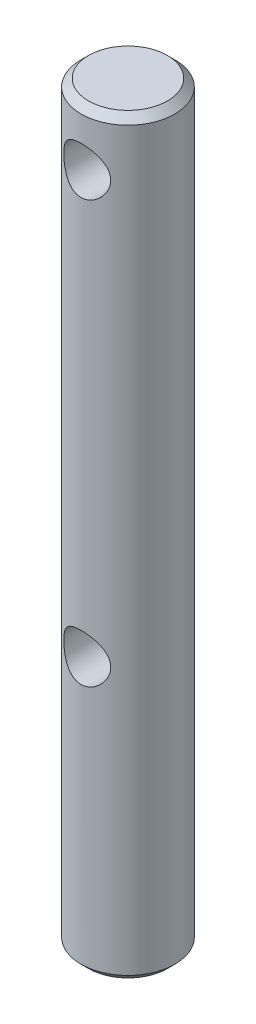
from build123d import *

# Parameters (mm, degrees)
SKETCH1_R               = 3.175
BOSS_EXTRUDE1_DEPTH     = 50.8
CHAMFER1_SIZE           = 0.508
CUT_EXTRUDE1_DEPTH      = 50.8
CUT_EXTRUDE1_DEPTH_BACK = 50.8
SKETCH2_R               = 1.5875


with BuildPart() as part:
    # Sketch1 → Boss-Extrude1 (new body)
    with BuildSketch(Plane(origin=(0, 0, 0), x_dir=(1, 0, 0), z_dir=(0, 1, 0))):
        Circle(SKETCH1_R)
    extrude(amount=BOSS_EXTRUDE1_DEPTH)

    # Chamfer1
    chamfer1_edges = [part.edges().sort_by_distance(p)[0] for p in [
        (-3.175, 0, 0),
        (-3.175, 50.8, 0),
    ]]
    chamfer(chamfer1_edges, length=CHAMFER1_SIZE)

    # Sketch2 → Cut-Extrude1 (cut, two sides: drawn at the far end of the back side and taken through both)
    with BuildSketch(Plane.XY.offset(-CUT_EXTRUDE1_DEPTH_BACK)):
        with Locations((0, 46.99)):
            Circle(SKETCH2_R)
        with Locations((0, 18.4785)):
            Circle(SKETCH2_R)
    extrude(amount=CUT_EXTRUDE1_DEPTH + CUT_EXTRUDE1_DEPTH_BACK, mode=Mode.SUBTRACT)


solid = part.part
